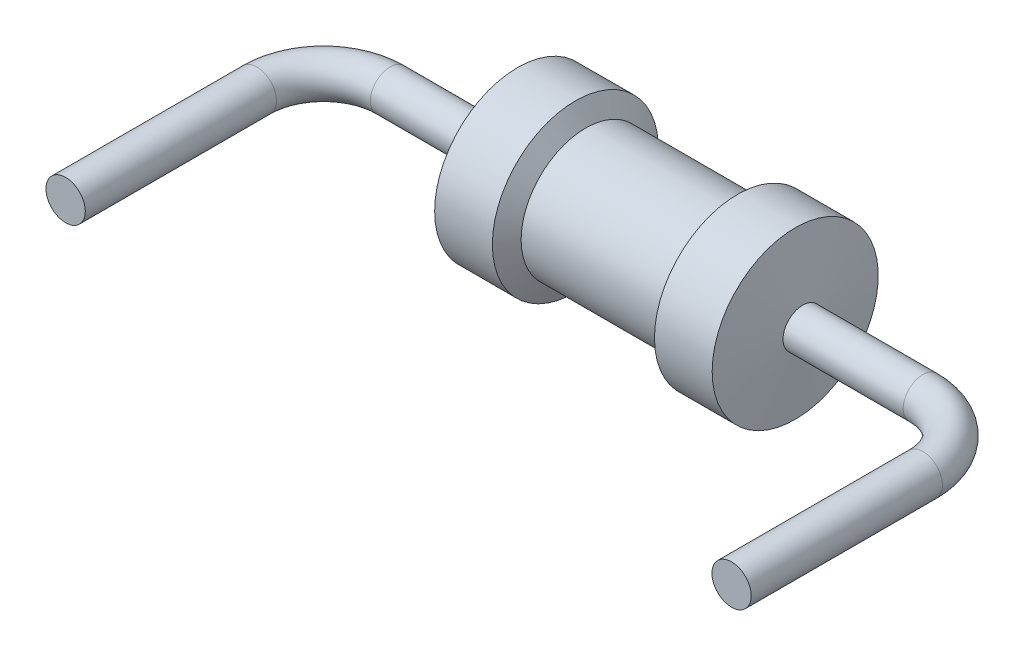
from build123d import *

# Parameters (mm, degrees)
SKETCH5_R           = 0.225
SKETCH6_R           = 0.225
BOSS_EXTRUDE2_DEPTH = 2


with BuildPart() as part:
    # Sketch1 → Revolve1 (revolve)
    with BuildSketch(Plane.XY):
        Polygon((2.11, 0), (2.222309461, 0.95), (2.882709461, 0.95), (3.001325793, 0.739819784), (4.618674207, 0.739819784), (4.737290539, 0.95), (5.397690539, 0.95), (5.51, 0), align=None)
    revolve(axis=Axis((0, 0, 0), (1, 0, 0)))

    # Sweep4: sweep along a path in Sketch3
    with BuildLine(Plane(origin=(0, 0, 0), x_dir=(1, 0, 0), z_dir=(0, 1, 0))) as sweep4_path:
        Line((0, -0.949999878), (0, -0.762))
        ThreePointArc((0, -0.762), (0.223184633, -0.223184633), (0.762, 0))
        Line((0.762, 0), (2.222309461, 0))
        Line((2.222309461, 0), (5.51, 0))
        Line((5.51, 0), (6.858, 0))
        ThreePointArc((6.858, 0), (7.396815367, -0.223184633), (7.62, -0.762))
        Line((7.62, -0.762), (7.62, -0.949999878))
    # Sketch5 → Sweep4 (sweep)
    with BuildSketch(Plane.XY.offset(0.949999878)):
        Circle(SKETCH5_R)
    sweep(path=sweep4_path.line)

    # Sketch6 → Boss-Extrude2 (add)
    with BuildSketch(Plane.XY.offset(0.949999878)):
        Circle(SKETCH6_R)
        with Locations((7.62, 0)):
            Circle(SKETCH6_R)
    extrude(amount=BOSS_EXTRUDE2_DEPTH)


solid = part.part
